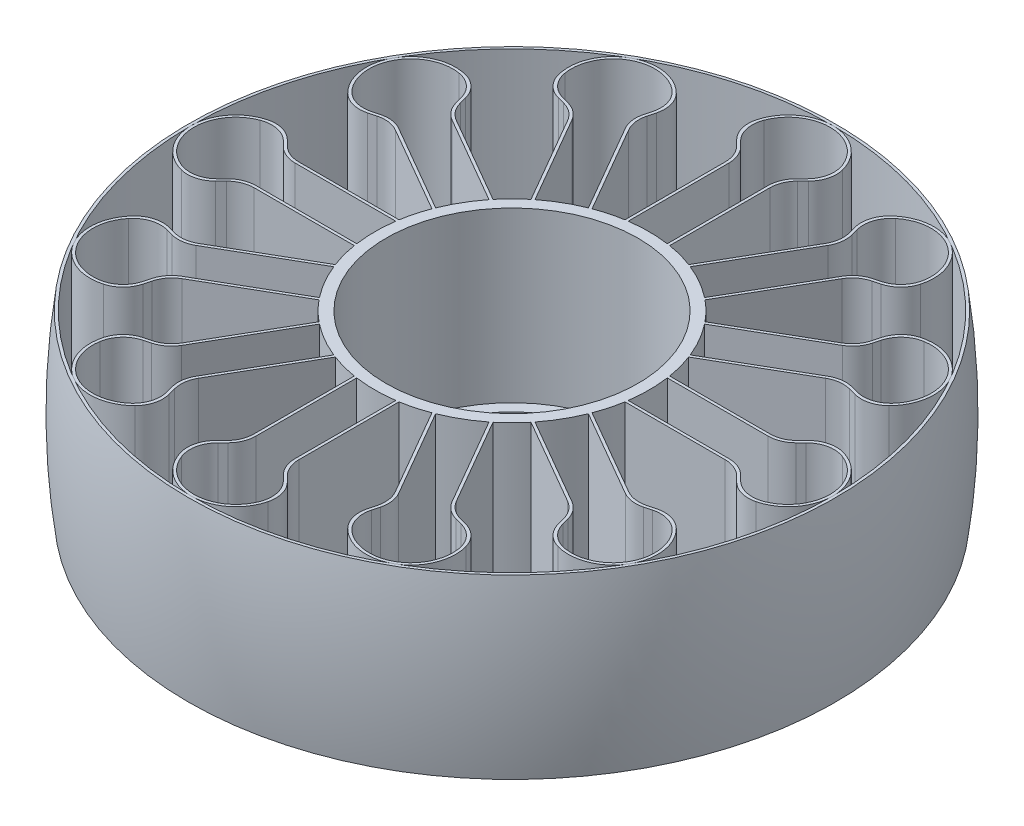
from build123d import *

# Parameters (mm, degrees)
BOSS_EXTRUDE1_DEPTH      = 31.7
FILLET1_R                = 5
CIRPATTERN1_COUNT        = 12
FILLET1_OF_CIRPATTERN1_R = 5


with BuildPart() as part:
    # Sketch1 → Revolve3 (revolve)
    with BuildSketch(Plane.XY, mode=Mode.PRIVATE) as revolve3_sk:
        Polygon((20.55, -14.35), (22.55, -14.35), (22.55, 15.85), (24.55, 15.85), (24.55, -15.85), (20.55, -15.85), align=None)
    revolve(revolve3_sk.sketch.rotate(Axis((0, 7.38603037, 0), (0, -1, 0)), 90), axis=Axis((0, 7.38603037, 0), (0, -1, 0)))

    # Sketch2 → Boss-Extrude1 (add)
    with BuildSketch(Plane(origin=(0, 15.85, 0), x_dir=(1, 0, 0), z_dir=(0, 1, 0))):
        with BuildLine():
            Line((-4, 44.221942532), (-4, 24.221942532))
            ThreePointArc((-4, 24.221942532), (-3.750199098, 24.26187352), (-3.5, 24.299228383))
            Line((-3.5, 24.299228383), (-3.5, 24.804283904))
            Line((-3.5, 24.804283904), (-3.5, 44.429049313))
            Line((-3.5, 44.429049313), (-7.420520845, 48.349570158))
            ThreePointArc((-7.420520845, 48.349570158), (0, 56.938546919), (7.420520845, 48.349570158))
            Line((7.420520845, 48.349570158), (3.5, 44.429049313))
            Line((3.5, 44.429049313), (3.5, 24.804283904))
            Line((3.5, 24.804283904), (3.5, 24.299228383))
            ThreePointArc((3.5, 24.299228383), (3.750199098, 24.26187352), (4, 24.221942532))
            Line((4, 24.221942532), (4, 44.221942532))
            Line((4, 44.221942532), (7.889087297, 48.111029828))
            ThreePointArc((7.889087297, 48.111029828), (0, 57.438546919), (-7.889087297, 48.111029828))
            Line((-7.889087297, 48.111029828), (-4, 44.221942532))
        make_face()
    boss_extrude1 = extrude(amount=-BOSS_EXTRUDE1_DEPTH)

    # Fillet1
    fillet1_edges = [part.edges().sort_by_distance(p)[0] for p in [
        (-7.420520845, 0, -48.349570158),
        (-3.5, 0, -44.429049313),
        (-4, 0, -44.221942532),
        (-7.889087297, 0, -48.111029828),
        (7.889087297, 0, -48.111029828),
        (4, 0, -44.221942532),
        (3.5, 0, -44.429049313),
        (7.420520845, 0, -48.349570158),
    ]]
    fillet(fillet1_edges, radius=FILLET1_R)

    # CirPattern1: Boss-Extrude1 ×12 about axis
    cirpattern1_axis = Axis((0, 0, 0), (0, 1, 0))
    for i in range(1, CIRPATTERN1_COUNT):
        add(boss_extrude1.rotate(cirpattern1_axis, i * 360 / CIRPATTERN1_COUNT))

    # Fillet1 of CirPattern1
    fillet1_of_cirpattern1_edges = [part.edges().sort_by_distance(p)[0] for p in [
        (-30.60114464, 0, -38.161695596),
        (-25.24561357, 0, -36.726685371),
        (-25.575072881, 0, -36.297325637),
        (-30.887664925, 0, -37.720830385),
        (-17.223364903, 0, -45.609917682),
        (-18.646869651, 0, -40.297325637),
        (-19.183435743, 0, -40.226685371),
        (-17.748425518, 0, -45.582216441),
        (-45.582216441, 0, -17.748425518),
        (-40.226685371, 0, -19.183435743),
        (-40.297325637, 0, -18.646869651),
        (-45.609917682, 0, -17.223364903),
        (-37.720830385, 0, -30.887664925),
        (-36.297325637, 0, -25.575072881),
        (-36.726685371, 0, -25.24561357),
        (-38.161695596, 0, -30.60114464),
        (-48.349570158, 0, 7.420520845),
        (-44.429049313, 0, 3.5),
        (-44.221942532, 0, 4),
        (-48.111029828, 0, 7.889087297),
        (-48.111029828, 0, -7.889087297),
        (-44.221942532, 0, -4),
        (-44.429049313, 0, -3.5),
        (-48.349570158, 0, -7.420520845),
        (-38.161695596, 0, 30.60114464),
        (-36.726685371, 0, 25.24561357),
        (-36.297325637, 0, 25.575072881),
        (-37.720830385, 0, 30.887664925),
        (-45.609917682, 0, 17.223364903),
        (-40.297325637, 0, 18.646869651),
        (-40.226685371, 0, 19.183435743),
        (-45.582216441, 0, 17.748425518),
        (-17.748425518, 0, 45.582216441),
        (-19.183435743, 0, 40.226685371),
        (-18.646869651, 0, 40.297325637),
        (-17.223364903, 0, 45.609917682),
        (-30.887664925, 0, 37.720830385),
        (-25.575072881, 0, 36.297325637),
        (-25.24561357, 0, 36.726685371),
        (-30.60114464, 0, 38.161695596),
        (7.420520845, 0, 48.349570158),
        (3.5, 0, 44.429049313),
        (4, 0, 44.221942532),
        (7.889087297, 0, 48.111029828),
        (-7.889087297, 0, 48.111029828),
        (-4, 0, 44.221942532),
        (-3.5, 0, 44.429049313),
        (-7.420520845, 0, 48.349570158),
        (30.60114464, 0, 38.161695596),
        (25.24561357, 0, 36.726685371),
        (25.575072881, 0, 36.297325637),
        (30.887664925, 0, 37.720830385),
        (17.223364903, 0, 45.609917682),
        (18.646869651, 0, 40.297325637),
        (19.183435743, 0, 40.226685371),
        (17.748425518, 0, 45.582216441),
        (45.582216441, 0, 17.748425518),
        (40.226685371, 0, 19.183435743),
        (40.297325637, 0, 18.646869651),
        (45.609917682, 0, 17.223364903),
        (37.720830385, 0, 30.887664925),
        (36.297325637, 0, 25.575072881),
        (36.726685371, 0, 25.24561357),
        (38.161695596, 0, 30.60114464),
        (48.349570158, 0, -7.420520845),
        (44.429049313, 0, -3.5),
        (44.221942532, 0, -4),
        (48.111029828, 0, -7.889087297),
        (48.111029828, 0, 7.889087297),
        (44.221942532, 0, 4),
        (44.429049313, 0, 3.5),
        (48.349570158, 0, 7.420520845),
        (38.161695596, 0, -30.60114464),
        (36.726685371, 0, -25.24561357),
        (36.297325637, 0, -25.575072881),
        (37.720830385, 0, -30.887664925),
        (45.609917682, 0, -17.223364903),
        (40.297325637, 0, -18.646869651),
        (40.226685371, 0, -19.183435743),
        (45.582216441, 0, -17.748425518),
        (17.748425518, 0, -45.582216441),
        (19.183435743, 0, -40.226685371),
        (18.646869651, 0, -40.297325637),
        (17.223364903, 0, -45.609917682),
        (30.887664925, 0, -37.720830385),
        (25.575072881, 0, -36.297325637),
        (25.24561357, 0, -36.726685371),
        (30.60114464, 0, -38.161695596),
    ]]
    fillet(fillet1_of_cirpattern1_edges, radius=FILLET1_OF_CIRPATTERN1_R)


with BuildPart() as body_2:
    # Sketch3 → Revolve4 (revolve)
    with BuildSketch(Plane(origin=(0, 0, 0), x_dir=(0, 0, -1), z_dir=(1, 0, 0)), mode=Mode.PRIVATE) as revolve4_sk:
        with BuildLine():
            Line((57.438546919, 15.85), (57.438546919, -15.85))
            Line((57.438546919, -15.85), (57.938546919, -15.85))
            ThreePointArc((57.938546919, -15.85), (58.998837597, 0), (57.938546919, 15.85))
            Line((57.938546919, 15.85), (57.438546919, 15.85))
        make_face()
    revolve(revolve4_sk.sketch.rotate(Axis((0, 24.965151845, 0), (0, -1, 0)), 180), axis=Axis((0, 24.965151845, 0), (0, -1, 0)))


solid = Compound([part.part, body_2.part])
